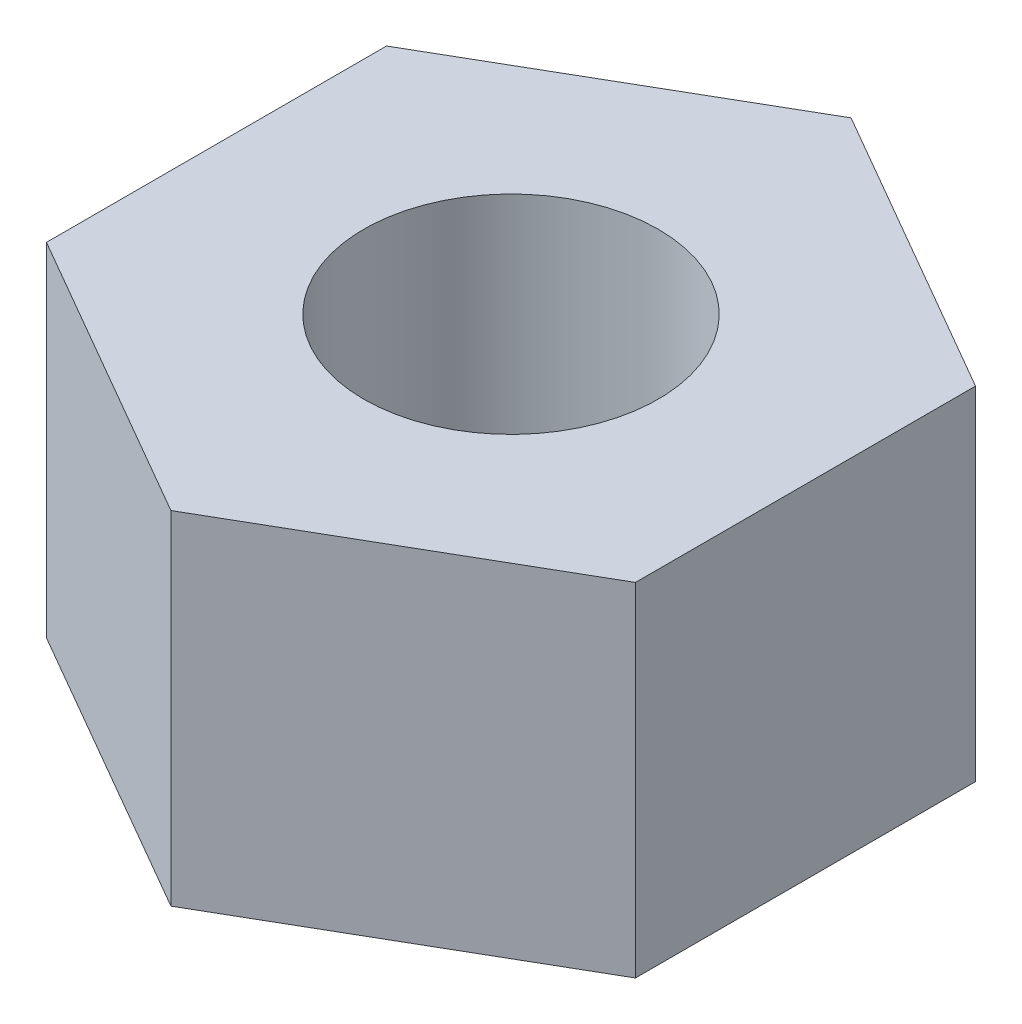
from build123d import *

# Parameters (mm, degrees)
SKETCH1_R           = 0.98
BOSS_EXTRUDE1_DEPTH = 2.28


with BuildPart() as part:
    # Sketch1 → Boss-Extrude1 (new body)
    with BuildSketch(Plane(origin=(0, 0, 0), x_dir=(1, 0, 0), z_dir=(0, 1, 0))):
        Polygon((0, -2.263213055), (1.96, -1.131606528), (1.96, 1.131606528), (0, 2.263213055), (-1.96, 1.131606528), (-1.96, -1.131606528), align=None)
        Circle(SKETCH1_R, mode=Mode.SUBTRACT)
    extrude(amount=BOSS_EXTRUDE1_DEPTH)


solid = part.part
